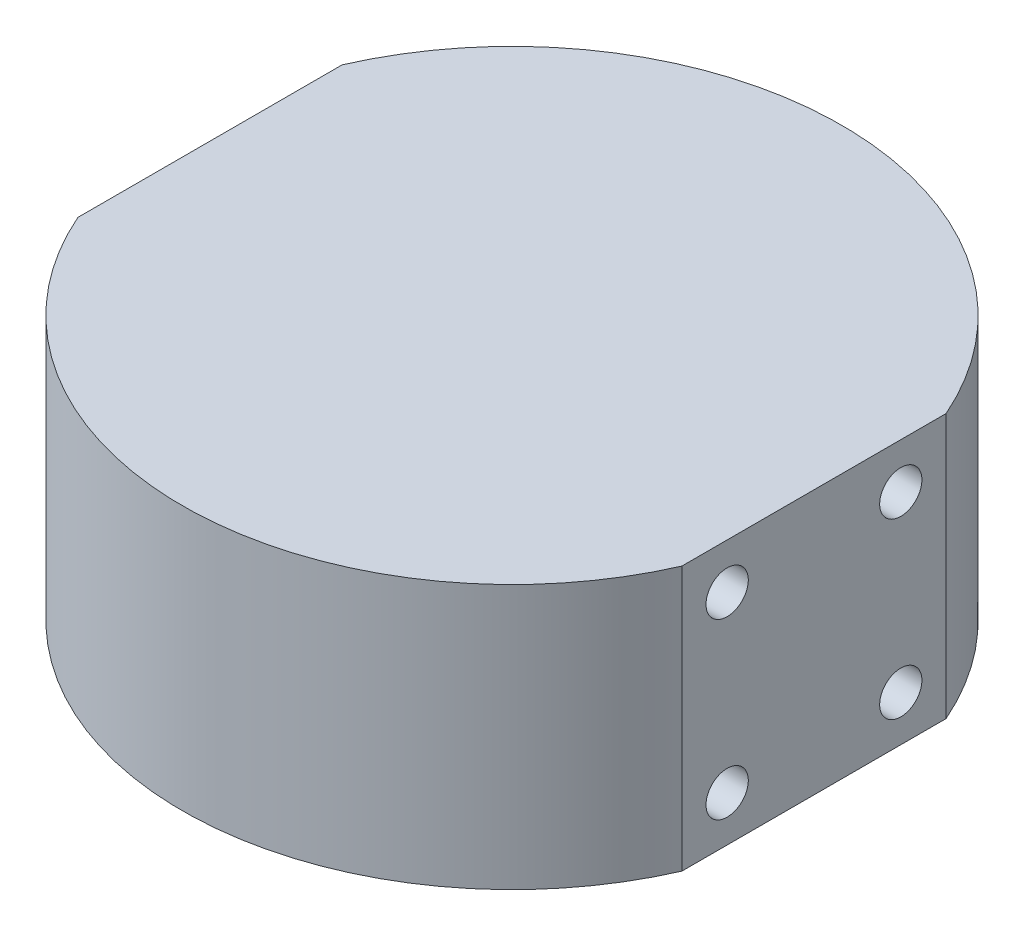
from build123d import *

# Parameters (mm, degrees)
BOSS_EXTRUDE1_DEPTH = 35
SKETCH2_R           = 2.8
CUT_EXTRUDE1_DEPTH  = 10
CUT_EXTRUDE2_START  = -80
SKETCH2_2_R         = 2.8
CUT_EXTRUDE2_DEPTH  = 10


with BuildPart() as part:
    # Sketch1 → Boss-Extrude1 (new body)
    with BuildSketch(Plane(origin=(0, 0, 0), x_dir=(1, 0, 0), z_dir=(0, 1, 0))):
        with BuildLine():
            Line((-40, 17.5), (-40, -17.5))
            ThreePointArc((-40, -17.5), (0, -43.660622991), (40, -17.5))
            Line((40, -17.5), (40, 17.5))
            ThreePointArc((40, 17.5), (0, 43.660622991), (-40, 17.5))
        make_face()
    extrude(amount=BOSS_EXTRUDE1_DEPTH)

    # Sketch2 → Cut-Extrude1 (cut)
    with BuildSketch(Plane.ZY.offset(40)):
        with Locations((-11.5, 29)):
            Circle(SKETCH2_R)
        with Locations((11.5, 29)):
            Circle(SKETCH2_R)
        with Locations((-11.5, 6)):
            Circle(SKETCH2_R)
        with Locations((11.5, 6)):
            Circle(SKETCH2_R)
    extrude(amount=-CUT_EXTRUDE1_DEPTH, mode=Mode.SUBTRACT)

    # Sketch2_2 → Cut-Extrude2 (cut)
    with BuildSketch(Plane.ZY.offset(40).offset(CUT_EXTRUDE2_START)):
        with Locations((-11.5, 29)):
            Circle(SKETCH2_2_R)
        with Locations((11.5, 29)):
            Circle(SKETCH2_2_R)
        with Locations((-11.5, 6)):
            Circle(SKETCH2_2_R)
        with Locations((11.5, 6)):
            Circle(SKETCH2_2_R)
    extrude(amount=CUT_EXTRUDE2_DEPTH, mode=Mode.SUBTRACT)


solid = part.part
